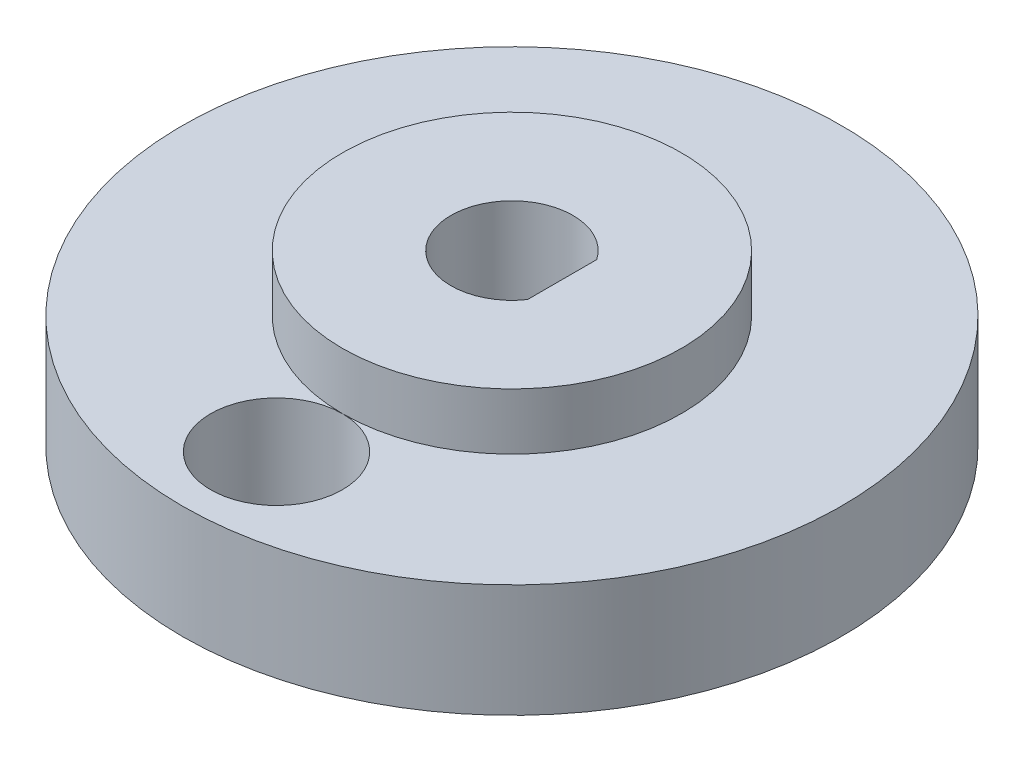
from build123d import *

# Parameters (mm, degrees)
SKETCH1_R           = 17.5
BOSS_EXTRUDE1_DEPTH = 6
SKETCH3_R           = 9
BOSS_EXTRUDE2_DEPTH = 3
CUT_EXTRUDE1_DEPTH  = 10
SKETCH5_R           = 3.5
CUT_EXTRUDE2_DEPTH  = 10


with BuildPart() as part:
    # Sketch1 → Boss-Extrude1 (new body)
    with BuildSketch(Plane(origin=(0, 0, 0), x_dir=(1, 0, 0), z_dir=(0, 1, 0))):
        Circle(SKETCH1_R)
    extrude(amount=BOSS_EXTRUDE1_DEPTH)

    # Sketch3 → Boss-Extrude2 (add)
    with BuildSketch(Plane(origin=(0, 6, 0), x_dir=(1, 0, 0), z_dir=(0, 1, 0))):
        Circle(SKETCH3_R)
    extrude(amount=BOSS_EXTRUDE2_DEPTH)

    # Sketch4 → Cut-Extrude1 (cut, through all)
    with BuildSketch(Plane(origin=(0, 9, 0), x_dir=(1, 0, 0), z_dir=(0, 1, 0))):
        with BuildLine():
            Line((2.667, -1.83711547), (2.667, 1.83711547))
            ThreePointArc((2.667, 1.83711547), (-3.2385, 0), (2.667, -1.83711547))
        make_face()
    extrude(amount=-CUT_EXTRUDE1_DEPTH, mode=Mode.SUBTRACT)

    # Sketch5 → Cut-Extrude2 (cut, through all)
    with BuildSketch(Plane(origin=(0, 0, 0), x_dir=(1, 0, 0), z_dir=(0, 1, 0))):
        with Locations((0, -12.5)):
            Circle(SKETCH5_R)
    extrude(amount=CUT_EXTRUDE2_DEPTH, mode=Mode.SUBTRACT)


solid = part.part
